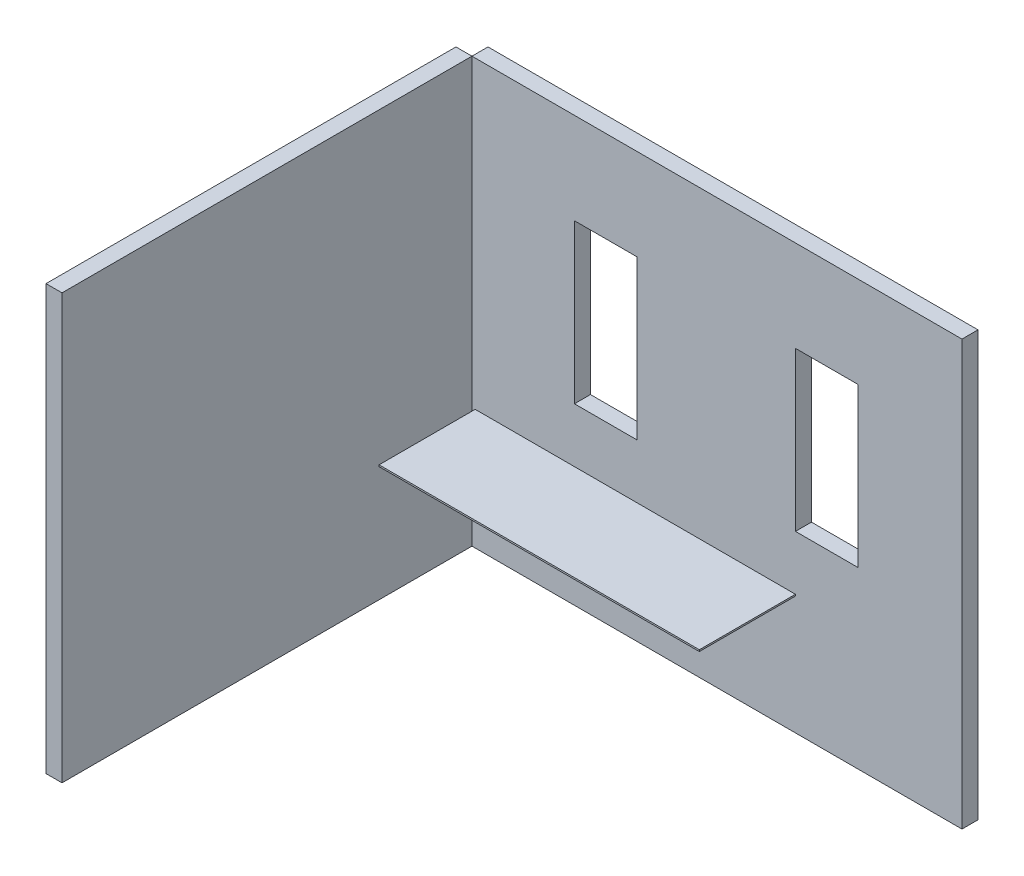
from build123d import *

# Parameters (mm, degrees)
ESBO_O6_W                = 3060
ESBO_O6_H                = 2650
RESSALTO_EXTRUS_O2_DEPTH = 100
ESBO_O7_W                = 390
ESBO_O7_H                = 990
CORTE_EXTRUS_O1_DEPTH    = 749
ESBO_O8_W                = 100
ESBO_O8_H                = 2650
RESSALTO_EXTRUS_O3_DEPTH = 2560
ESBO_O14_W               = 2000
ESBO_O14_H               = 10
RESSALTO_EXTRUS_O5_DEPTH = 600


with BuildPart() as part:
    # Esboço6 → Ressalto-extrusão2 (new body)
    with BuildSketch(Plane.XY):
        with Locations((1530, 1325)):
            Rectangle(ESBO_O6_W, ESBO_O6_H)
    extrude(amount=RESSALTO_EXTRUS_O2_DEPTH)

    # Esboço7 → Corte-extrusão1 (cut)
    with BuildSketch(Plane.XY.offset(100)):
        with Locations((2215, 1585)):
            Rectangle(ESBO_O7_W, ESBO_O7_H)
        with Locations((835, 1585)):
            Rectangle(ESBO_O7_W, ESBO_O7_H)
    extrude(amount=-CORTE_EXTRUS_O1_DEPTH, mode=Mode.SUBTRACT)

    # Esboço14 → Ressalto-extrusão5 (add)
    with BuildSketch(Plane.XY.offset(100)):
        with Locations((1020, 745)):
            Rectangle(ESBO_O14_W, ESBO_O14_H)
    extrude(amount=RESSALTO_EXTRUS_O5_DEPTH)


with BuildPart() as body_2:
    # Esboço8 → Ressalto-extrusão3 (new body)
    with BuildSketch(Plane.XY.offset(100)):
        with Locations((-50, 1325)):
            Rectangle(ESBO_O8_W, ESBO_O8_H)
    extrude(amount=RESSALTO_EXTRUS_O3_DEPTH)


solid = Compound([part.part, body_2.part])
